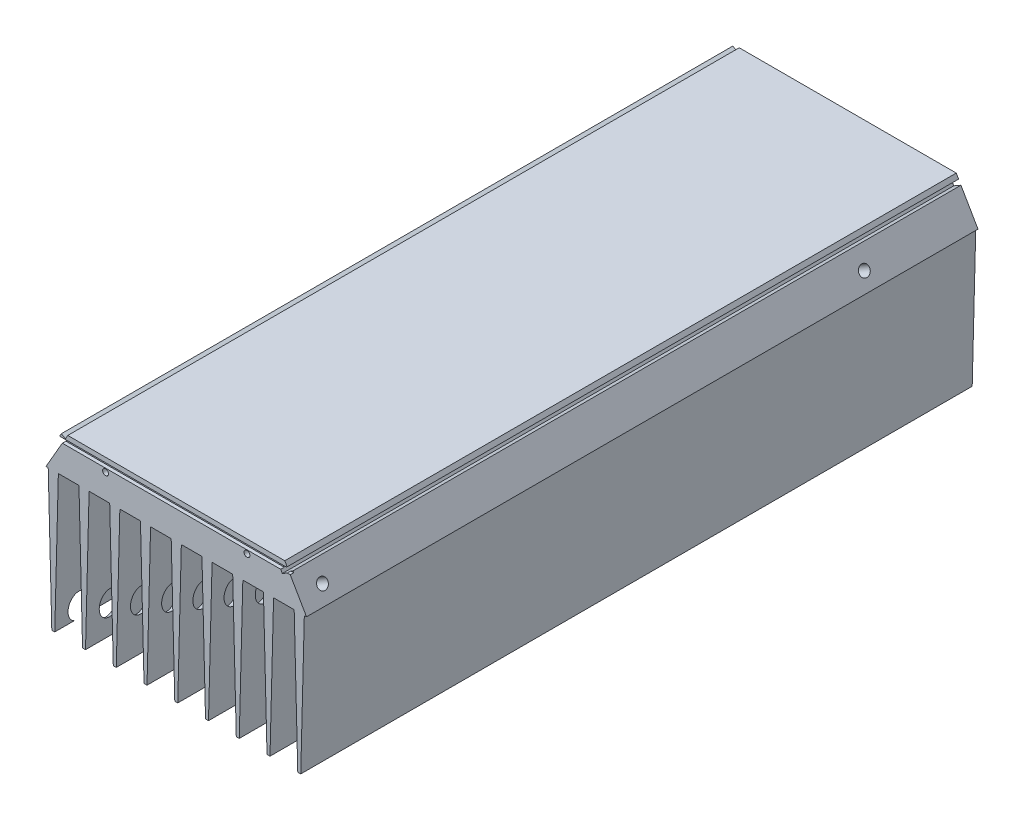
from build123d import *

# Parameters (mm, degrees)
RESSALTO_EXTRUS_O1_DEPTH   = 285
CORTE_EXTRUS_O1_DEPTH      = 1
CORTE_EXTRUS_O1_DEPTH_BACK = 286
ESBO_O3_R                  = 2.25
CORTE_EXTRUS_O2_DEPTH      = 130
ESBO_O4_R                  = 1.645507678
CORTE_EXTRUS_O3_DEPTH      = 15
ESBO_O5_R                  = 3.5
CORTE_EXTRUS_O4_DEPTH      = 10
CORTE_EXTRUS_O5_START      = -10
ESBO_O6_R                  = 4.5
CORTE_EXTRUS_O5_DEPTH      = 120
ESBO_O7_W                  = 1.5
ESBO_O7_H                  = 2
CORTE_EXTRUS_O6_DEPTH      = 124.176451884
CORTE_EXTRUS_O6_DEPTH_BACK = 1
ESBO_O8_R                  = 1.25
CORTE_EXTRUS_O7_DEPTH      = 10


with BuildPart() as part:
    # Esboço1 → Ressalto-extrusão1 (new body)
    with BuildSketch(Plane.XY):
        Polygon((0, 75), (135.77, 75), (135.77, 0), (132.504208406, 0), (130.985, 59), (122.235, 59), (120.715791594, 0), (119.454208406, 0), (117.935, 59), (109.185, 59), (107.665791594, 0), (106.404208406, 0), (104.885, 59), (96.135, 59), (94.615791594, 0), (93.354208406, 0), (91.835, 59), (83.085, 59), (81.565791594, 0), (80.304208406, 0), (78.785, 59), (70.035, 59), (68.515791594, 0), (67.254208406, 0), (65.735, 59), (56.985, 59), (55.465791594, 0), (54.204208406, 0), (52.685, 59), (43.935, 59), (42.415791594, 0), (41.154208406, 0), (39.635, 59), (30.885, 59), (29.365791594, 0), (28.104208406, 0), (26.585, 59), (17.835, 59), (16.315791594, 0), (15.054208406, 0), (13.535, 59), (4.785, 59), (3.265791594, 0), (0, 0), align=None)
    extrude(amount=RESSALTO_EXTRUS_O1_DEPTH)

    # Esboço2 → Corte-extrusão1 (cut, two sides)
    with BuildSketch(Plane(origin=(0, 0, 0), x_dir=(-1, 0, 0), z_dir=(0, 0, -1))) as corte_extrus_o1_sk:
        Polygon((-21.831152423, 75), (-20.831152423, 73.267949192), (-19.099101615, 74.267949192), (-18.099101615, 72.535898385), (-19.831152423, 71.535898385), (-12.593548116, 59), (-12.593548116, -2.874547604), (9.502168499, -2.874547604), (9.502168499, 75), align=None)
        Polygon((-113.938847577, 75), (-114.938847577, 73.267949192), (-111.907758664, 71.517949192), (-112.907758664, 69.785898385), (-115.938847577, 71.535898385), (-123.176451884, 59), (-123.176451884, -2.874547604), (-142.207346128, -2.874547604), (-142.207346128, 78.515038313), (-113.938847577, 78.515038313), align=None)
    extrude(amount=CORTE_EXTRUS_O1_DEPTH, mode=Mode.SUBTRACT)
    extrude(corte_extrus_o1_sk.sketch, amount=-CORTE_EXTRUS_O1_DEPTH_BACK, mode=Mode.SUBTRACT)

    # Esboço3 → Corte-extrusão2 (cut)
    with BuildSketch(Plane(origin=(117.930088325, 68.08696824, 0), x_dir=(0, 0, -1), z_dir=(0.866025404, 0.5, 0))):
        with Locations((-275, -4.017518505)):
            Circle(ESBO_O3_R)
        with Locations((-45, -4.017518505)):
            Circle(ESBO_O3_R)
    extrude(amount=-CORTE_EXTRUS_O2_DEPTH, mode=Mode.SUBTRACT)

    # Esboço4 → Corte-extrusão3 (cut)
    with BuildSketch(Plane(origin=(-16.102588325, 9.296833704, 0), x_dir=(0, 0, 1), z_dir=(-0.866025404, 0.5, 0))):
        with Locations((45, 63.867481495)):
            Circle(ESBO_O4_R)
        with Locations((275, 63.867481495)):
            Circle(ESBO_O4_R)
    extrude(amount=-CORTE_EXTRUS_O3_DEPTH, mode=Mode.SUBTRACT)

    # Esboço5 → Corte-extrusão4 (cut)
    with BuildSketch(Plane(origin=(0, 0, 0), x_dir=(-1, 0, 0), z_dir=(0, 0, -1))):
        with Locations((-67.885, 49.767603925)):
            Circle(ESBO_O5_R)
    extrude(amount=-CORTE_EXTRUS_O4_DEPTH, mode=Mode.SUBTRACT)

    # Esboço6 → Corte-extrusão5 (cut)
    with BuildSketch(Plane(origin=(117.930088325, 68.08696824, 0), x_dir=(0, 0, -1), z_dir=(0.866025404, 0.5, 0)).offset(CORTE_EXTRUS_O5_START)):
        with Locations((-275, -4.017518505)):
            Circle(ESBO_O6_R)
        with Locations((-45, -4.017518505)):
            Circle(ESBO_O6_R)
    extrude(amount=-CORTE_EXTRUS_O5_DEPTH, mode=Mode.SUBTRACT)

    # Esboço7 → Corte-extrusão6 (cut, two sides)
    with BuildSketch(Plane(origin=(0, 36.48769631, 0), x_dir=(0, 0, -1), z_dir=(1, 0, 0))) as corte_extrus_o6_sk:
        with Locations((-284.25, 35.51230369)):
            Rectangle(ESBO_O7_W, ESBO_O7_H)
    extrude(amount=CORTE_EXTRUS_O6_DEPTH, mode=Mode.SUBTRACT)
    extrude(corte_extrus_o6_sk.sketch, amount=-CORTE_EXTRUS_O6_DEPTH_BACK, mode=Mode.SUBTRACT)

    # Esboço8 → Corte-extrusão7 (cut)
    with BuildSketch(Plane.XY.offset(285)):
        with Locations((37.885, 69.5)):
            Circle(ESBO_O8_R)
        with Locations((97.885, 69.5)):
            Circle(ESBO_O8_R)
    extrude(amount=-CORTE_EXTRUS_O7_DEPTH, mode=Mode.SUBTRACT)


solid = part.part
